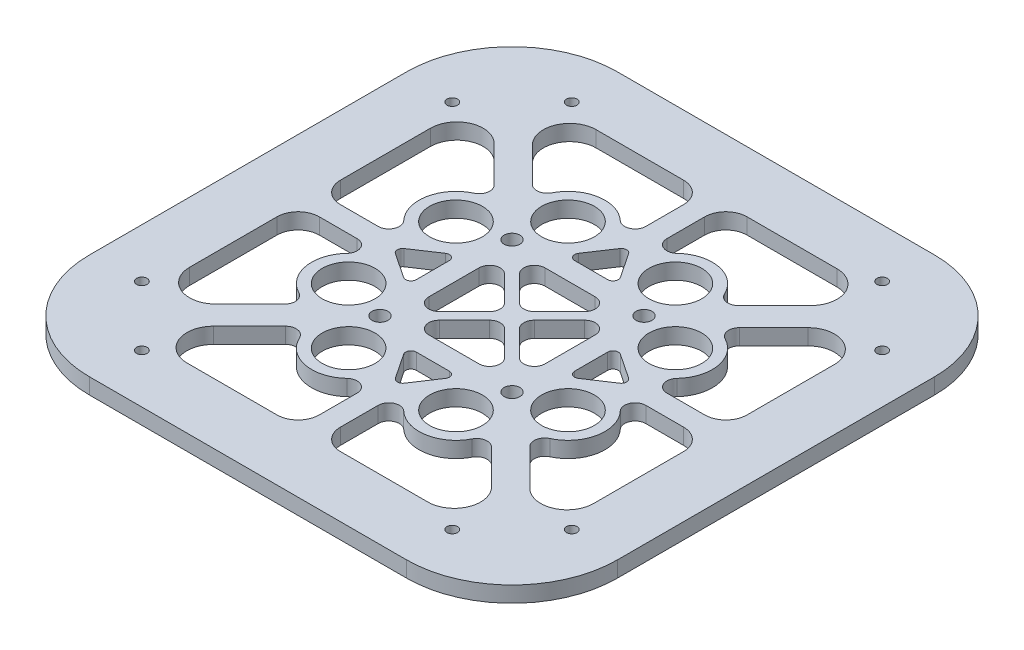
from build123d import *

# Parameters (mm, degrees)
ESQUISSE1_W        = 100
ESQUISSE1_H        = 100
ESQUISSE1_R        = 5
ESQUISSE1_R_2      = 1.5
ESQUISSE1_R_3      = 1
BOSS_EXTRU_1_DEPTH = 3
CONG_1_R           = 20
CONG_2_R           = 5
CONG_3_R           = 4
CONG_4_R           = 2
CONG_5_R           = 1


with BuildPart() as part:
    # Esquisse1 → Boss.-Extru.1 (new body)
    with BuildSketch(Plane(origin=(0, 0, 0), x_dir=(1, 0, 0), z_dir=(0, 1, 0))):
        Rectangle(ESQUISSE1_W, ESQUISSE1_H)
        with Locations((-10.165686226, -20.772287944)):
            Circle(ESQUISSE1_R, mode=Mode.SUBTRACT)
        with Locations((10.165686226, -20.772287944)):
            Circle(ESQUISSE1_R, mode=Mode.SUBTRACT)
        with Locations((-20.772287944, 10.165686226)):
            Circle(ESQUISSE1_R, mode=Mode.SUBTRACT)
        with Locations((-20.772287944, -10.165686226)):
            Circle(ESQUISSE1_R, mode=Mode.SUBTRACT)
        with Locations((10.165686226, 20.772287944)):
            Circle(ESQUISSE1_R, mode=Mode.SUBTRACT)
        with Locations((-10.165686226, 20.772287944)):
            Circle(ESQUISSE1_R, mode=Mode.SUBTRACT)
        with Locations((20.772287944, -10.165686226)):
            Circle(ESQUISSE1_R, mode=Mode.SUBTRACT)
        with Locations((20.772287944, 10.165686226)):
            Circle(ESQUISSE1_R, mode=Mode.SUBTRACT)
        with Locations((-12.5, -12.5)):
            Circle(ESQUISSE1_R_2, mode=Mode.SUBTRACT)
        with Locations((12.5, -12.5)):
            Circle(ESQUISSE1_R_2, mode=Mode.SUBTRACT)
        with Locations((12.5, 12.5)):
            Circle(ESQUISSE1_R_2, mode=Mode.SUBTRACT)
        with Locations((-12.5, 12.5)):
            Circle(ESQUISSE1_R_2, mode=Mode.SUBTRACT)
        with Locations((29.393398282, -40.707106781)):
            Circle(ESQUISSE1_R_3, mode=Mode.SUBTRACT)
        with Locations((40.707106781, -29.393398282)):
            Circle(ESQUISSE1_R_3, mode=Mode.SUBTRACT)
        with Locations((-40.707106781, -29.393398282)):
            Circle(ESQUISSE1_R_3, mode=Mode.SUBTRACT)
        with Locations((-29.393398282, -40.707106781)):
            Circle(ESQUISSE1_R_3, mode=Mode.SUBTRACT)
        with Locations((-29.393398282, 40.707106781)):
            Circle(ESQUISSE1_R_3, mode=Mode.SUBTRACT)
        with Locations((-40.707106781, 29.393398282)):
            Circle(ESQUISSE1_R_3, mode=Mode.SUBTRACT)
        with Locations((40.707106781, 29.393398282)):
            Circle(ESQUISSE1_R_3, mode=Mode.SUBTRACT)
        with Locations((29.393398282, 40.707106781)):
            Circle(ESQUISSE1_R_3, mode=Mode.SUBTRACT)
        Polygon((-15, 5), (-15, -5), (-22.5, 0), align=None, mode=Mode.SUBTRACT)
        Polygon((-5, -15), (5, -15), (0, -22.5), align=None, mode=Mode.SUBTRACT)
        Polygon((0, -1.414213562), (-9.585786438, -11), (9.585786438, -11), align=None, mode=Mode.SUBTRACT)
        with BuildLine():
            Line((-35.121298691, -38.5), (-2, -38.5))
            Line((-2, -38.5), (-2, -21))
            Line((-2, -21), (-4.270210369, -24.546326156))
            ThreePointArc((-4.270210369, -24.546326156), (-12.242808638, -27.457014003), (-17.161849304, -20.540550613))
            Line((-17.161849304, -20.540550613), (-35.121298691, -38.5))
        make_face(mode=Mode.SUBTRACT)
        with BuildLine():
            Line((2, -38.5), (2, -21))
            Line((2, -21), (4.270210369, -24.546326156))
            ThreePointArc((4.270210369, -24.546326156), (12.0097075, -27.525034462), (17.161082424, -21.026122599))
            Line((17.161082424, -21.026122599), (34.634959825, -38.5))
            Line((34.634959825, -38.5), (2, -38.5))
        make_face(mode=Mode.SUBTRACT)
        Polygon((-1.414213562, 0), (-11, 9.585786438), (-11, -9.585786438), align=None, mode=Mode.SUBTRACT)
        with BuildLine():
            Line((-38.5, 35.121298691), (-38.5, 2))
            Line((-38.5, 2), (-21, 2))
            Line((-21, 2), (-24.546326156, 4.270210369))
            ThreePointArc((-24.546326156, 4.270210369), (-27.457014003, 12.242808638), (-20.540550613, 17.161849304))
            Line((-20.540550613, 17.161849304), (-38.5, 35.121298691))
        make_face(mode=Mode.SUBTRACT)
        with BuildLine():
            Line((-38.5, -2), (-21, -2))
            Line((-21, -2), (-24.546326156, -4.270210369))
            ThreePointArc((-24.546326156, -4.270210369), (-27.525034462, -12.0097075), (-21.026122599, -17.161082424))
            Line((-21.026122599, -17.161082424), (-38.5, -34.634959825))
            Line((-38.5, -34.634959825), (-38.5, -2))
        make_face(mode=Mode.SUBTRACT)
        Polygon((0, 1.414213562), (9.585786438, 11), (-9.585786438, 11), align=None, mode=Mode.SUBTRACT)
        Polygon((5, 15), (-5, 15), (0, 22.5), align=None, mode=Mode.SUBTRACT)
        with BuildLine():
            Line((35.121298691, 38.5), (2, 38.5))
            Line((2, 38.5), (2, 21))
            Line((2, 21), (4.270210369, 24.546326156))
            ThreePointArc((4.270210369, 24.546326156), (12.242808638, 27.457014003), (17.161849304, 20.540550613))
            Line((17.161849304, 20.540550613), (35.121298691, 38.5))
        make_face(mode=Mode.SUBTRACT)
        with BuildLine():
            Line((-2, 38.5), (-2, 21))
            Line((-2, 21), (-4.270210369, 24.546326156))
            ThreePointArc((-4.270210369, 24.546326156), (-12.0097075, 27.525034462), (-17.161082424, 21.026122599))
            Line((-17.161082424, 21.026122599), (-34.634959825, 38.5))
            Line((-34.634959825, 38.5), (-2, 38.5))
        make_face(mode=Mode.SUBTRACT)
        Polygon((1.414213562, 0), (11, -9.585786438), (11, 9.585786438), align=None, mode=Mode.SUBTRACT)
        Polygon((15, -5), (15, 5), (22.5, 0), align=None, mode=Mode.SUBTRACT)
        with BuildLine():
            Line((38.5, -35.121298691), (38.5, -2))
            Line((38.5, -2), (21, -2))
            Line((21, -2), (24.546326156, -4.270210369))
            ThreePointArc((24.546326156, -4.270210369), (27.457014003, -12.242808638), (20.540550613, -17.161849304))
            Line((20.540550613, -17.161849304), (38.5, -35.121298691))
        make_face(mode=Mode.SUBTRACT)
        with BuildLine():
            Line((38.5, 2), (21, 2))
            Line((21, 2), (24.546326156, 4.270210369))
            ThreePointArc((24.546326156, 4.270210369), (27.525034462, 12.0097075), (21.026122599, 17.161082424))
            Line((21.026122599, 17.161082424), (38.5, 34.634959825))
            Line((38.5, 34.634959825), (38.5, 2))
        make_face(mode=Mode.SUBTRACT)
    extrude(amount=BOSS_EXTRU_1_DEPTH)

    # Congé1
    cong_1_edges = [part.edges().sort_by_distance(p)[0] for p in [
        (-50, 1.5, -50),
        (50, 1.5, -50),
        (50, 1.5, 50),
        (-50, 1.5, 50),
    ]]
    fillet(cong_1_edges, radius=CONG_1_R)

    # Congé2
    cong_2_edges = [part.edges().sort_by_distance(p)[0] for p in [
        (34.634959825, 1.5, 38.5),
        (38.5, 1.5, 35.121298691),
        (38.5, 1.5, -34.634959825),
        (35.121298691, 1.5, -38.5),
        (-38.5, 1.5, -35.121298691),
        (-34.634959825, 1.5, -38.5),
        (-38.5, 1.5, 34.634959825),
        (-35.121298691, 1.5, 38.5),
    ]]
    fillet(cong_2_edges, radius=CONG_2_R)

    # Congé3
    cong_3_edges = [part.edges().sort_by_distance(p)[0] for p in [
        (38.5, 1.5, -2),
        (38.5, 1.5, 2),
        (2, 1.5, 38.5),
        (-2, 1.5, 38.5),
        (-38.5, 1.5, 2),
        (-38.5, 1.5, -2),
        (2, 1.5, -38.5),
        (-2, 1.5, -38.5),
    ]]
    fillet(cong_3_edges, radius=CONG_3_R)

    # Congé4
    cong_4_edges = [part.edges().sort_by_distance(p)[0] for p in [
        (9.585786438, 1.5, 11),
        (-9.585786438, 1.5, 11),
        (11, 1.5, 9.585786438),
        (9.585786438, 1.5, -11),
        (11, 1.5, -9.585786438),
        (1.414213562, 1.5, 0),
        (-9.585786438, 1.5, -11),
        (0, 1.5, 1.414213562),
        (-11, 1.5, 9.585786438),
        (-1.414213562, 1.5, 0),
        (-11, 1.5, -9.585786438),
        (0, 1.5, -1.414213562),
        (-17.161082424, 1.5, -21.026122599),
        (-2, 1.5, -21),
        (2, 1.5, -21),
        (17.161849304, 1.5, -20.540550613),
        (21.026122599, 1.5, -17.161082424),
        (21, 1.5, -2),
        (21, 1.5, 2),
        (-21, 1.5, -2),
        (-21, 1.5, 2),
        (-21.026122599, 1.5, 17.161082424),
        (-17.161849304, 1.5, 20.540550613),
        (-2, 1.5, 21),
        (2, 1.5, 21),
        (17.161082424, 1.5, 21.026122599),
        (20.540550613, 1.5, 17.161849304),
        (-20.540550613, 1.5, -17.161849304),
    ]]
    fillet(cong_4_edges, radius=CONG_4_R)

    # Congé5
    cong_5_edges = [part.edges().sort_by_distance(p)[0] for p in [
        (15, 1.5, -5),
        (0, 1.5, -22.5),
        (-15, 1.5, -5),
        (5, 1.5, 15),
        (22.5, 1.5, 0),
        (5, 1.5, -15),
        (-15, 1.5, 5),
        (0, 1.5, 22.5),
        (15, 1.5, 5),
        (-5, 1.5, -15),
        (-22.5, 1.5, 0),
        (-5, 1.5, 15),
    ]]
    fillet(cong_5_edges, radius=CONG_5_R)


solid = part.part
